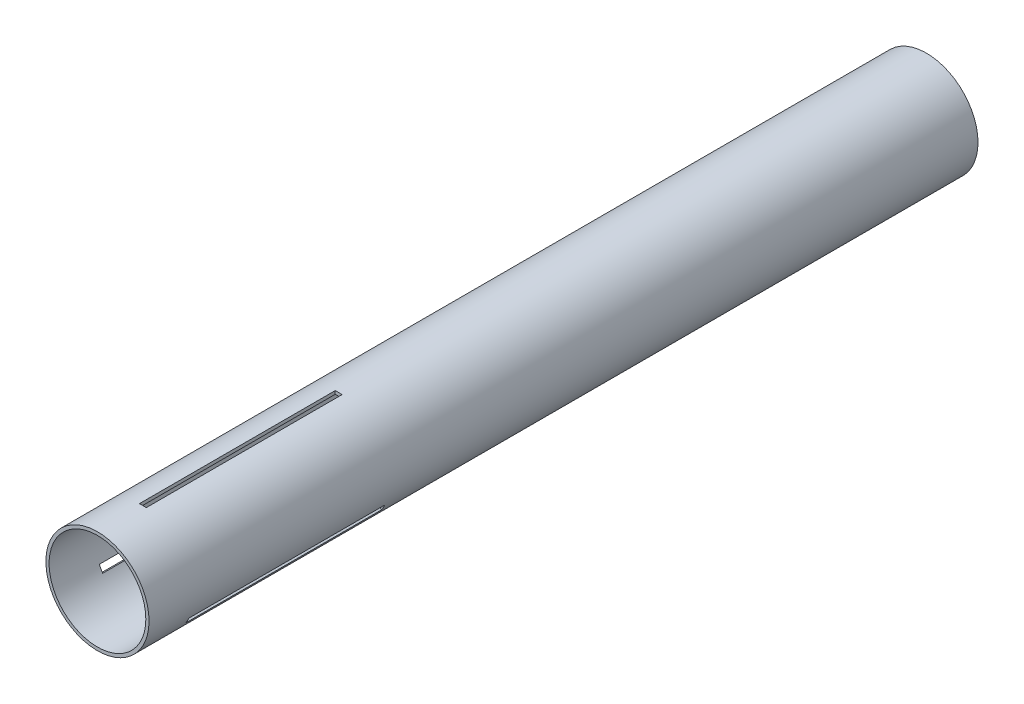
from build123d import *

# Parameters (mm, degrees)
SKETCH1_R           = 23.6982
SKETCH1_R_2         = 22.225
BOSS_EXTRUDE1_DEPTH = 381
CUT_EXTRUDE2_START  = -28.631769
SKETCH3_W           = 3.175
SKETCH3_H           = 89.9999978
CUT_EXTRUDE2_DEPTH  = 1.529969
CIRPATTERN4_COUNT   = 3


with BuildPart() as part:
    # Sketch1 → Boss-Extrude1 (new body)
    with BuildSketch(Plane.XY):
        Circle(SKETCH1_R)
        Circle(SKETCH1_R_2, mode=Mode.SUBTRACT)
    extrude(amount=BOSS_EXTRUDE1_DEPTH)

    # Sketch3 → Cut-Extrude2 (cut)
    with BuildSketch(Plane(origin=(0, 50.8, 0), x_dir=(1, 0, 0), z_dir=(0, 1, 0)).offset(CUT_EXTRUDE2_START)):
        with Locations((0, -315.1720011)):
            Rectangle(SKETCH3_W, SKETCH3_H)
    cut_extrude2 = extrude(amount=CUT_EXTRUDE2_DEPTH, mode=Mode.SUBTRACT)

    # CirPattern4: Cut-Extrude2 ×3 about axis
    cirpattern4_axis = Axis((0, 0, 0), (0, 0, 1))
    for i in range(1, CIRPATTERN4_COUNT):
        add(cut_extrude2.rotate(cirpattern4_axis, i * 360 / CIRPATTERN4_COUNT), mode=Mode.SUBTRACT)


solid = part.part
